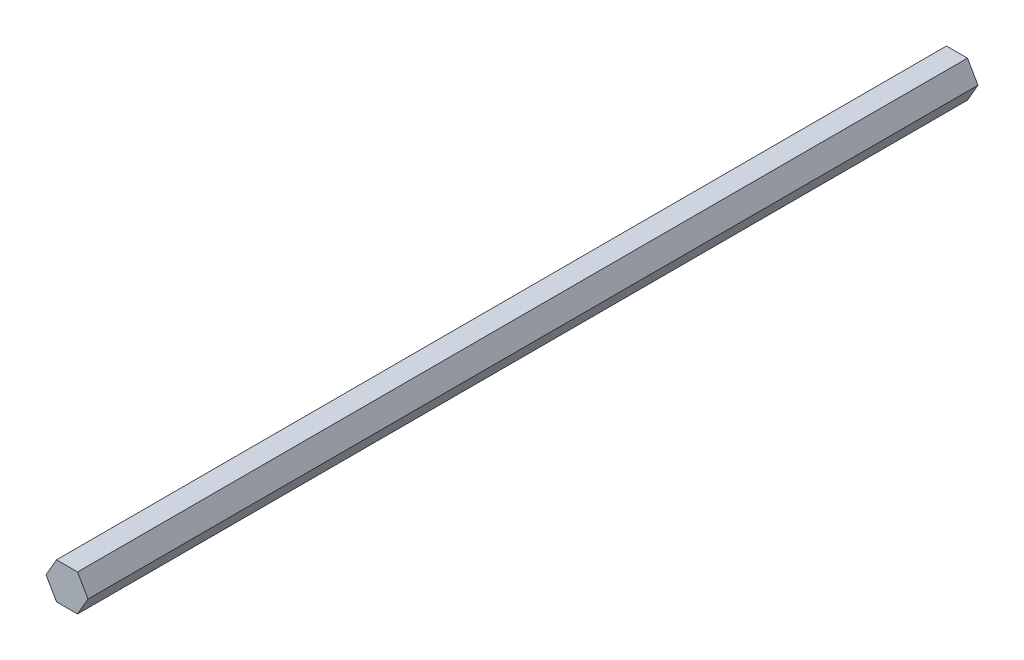
from build123d import *

# Parameters (mm, degrees)
BOSS_EXTRUDE1_DEPTH = 310.4


with BuildPart() as part:
    # Sketch1 → Boss-Extrude1 (new body)
    with BuildSketch(Plane.XY):
        Polygon((7.332348419, 0), (3.666174209, 6.35), (-3.666174209, 6.35), (-7.332348419, 0), (-3.666174209, -6.35), (3.666174209, -6.35), align=None)
    extrude(amount=BOSS_EXTRUDE1_DEPTH)


solid = part.part
